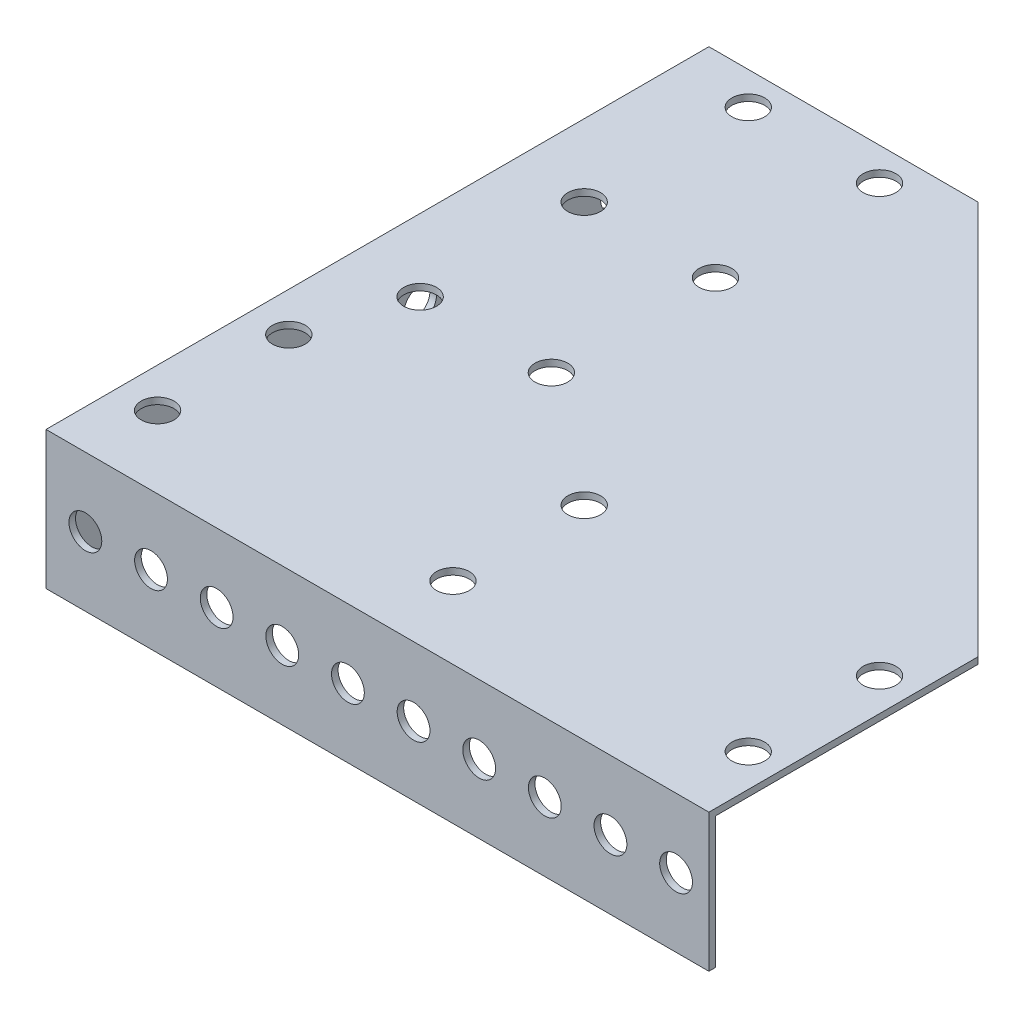
from build123d import *

# Parameters (mm, degrees)
SKETCH1_R           = 2.5
BOSS_EXTRUDE1_DEPTH = 1
SKETCH2_W           = 100
SKETCH2_H           = 21
SKETCH2_R           = 2.5
BOSS_EXTRUDE2_DEPTH = 1
SKETCH3_W           = 101
SKETCH3_H           = 21
SKETCH3_R           = 2.5
BOSS_EXTRUDE5_DEPTH = 1


with BuildPart() as part:
    # Sketch1 → Boss-Extrude1 (new body)
    with BuildSketch(Plane(origin=(0, 0, 0), x_dir=(1, 0, 0), z_dir=(0, 1, 0))):
        Polygon((0, 0), (0, -100), (100, -100), (100, -60), (40, 0), align=None)
        with Locations((10, -5)):
            Circle(SKETCH1_R, mode=Mode.SUBTRACT)
        with Locations((30, -5)):
            Circle(SKETCH1_R, mode=Mode.SUBTRACT)
        with Locations((30, -55)):
            Circle(SKETCH1_R, mode=Mode.SUBTRACT)
        with Locations((10, -55)):
            Circle(SKETCH1_R, mode=Mode.SUBTRACT)
        with Locations((30, -30)):
            Circle(SKETCH1_R, mode=Mode.SUBTRACT)
        with Locations((10, -30)):
            Circle(SKETCH1_R, mode=Mode.SUBTRACT)
        with Locations((50, -70)):
            Circle(SKETCH1_R, mode=Mode.SUBTRACT)
        with Locations((50, -90)):
            Circle(SKETCH1_R, mode=Mode.SUBTRACT)
        with Locations((95, -70)):
            Circle(SKETCH1_R, mode=Mode.SUBTRACT)
        with Locations((95, -90)):
            Circle(SKETCH1_R, mode=Mode.SUBTRACT)
        with Locations((5, -70)):
            Circle(SKETCH1_R, mode=Mode.SUBTRACT)
        with Locations((5, -90)):
            Circle(SKETCH1_R, mode=Mode.SUBTRACT)
    extrude(amount=BOSS_EXTRUDE1_DEPTH)

    # Sketch2 → Boss-Extrude2 (add)
    with BuildSketch(Plane.ZY):
        with Locations((50, -9.5)):
            Rectangle(SKETCH2_W, SKETCH2_H)
        with Locations((5, -10)):
            Circle(SKETCH2_R, mode=Mode.SUBTRACT)
        with Locations((15, -10)):
            Circle(SKETCH2_R, mode=Mode.SUBTRACT)
        with Locations((25, -10)):
            Circle(SKETCH2_R, mode=Mode.SUBTRACT)
        with Locations((35, -10)):
            Circle(SKETCH2_R, mode=Mode.SUBTRACT)
        with Locations((45, -10)):
            Circle(SKETCH2_R, mode=Mode.SUBTRACT)
        with Locations((55, -10)):
            Circle(SKETCH2_R, mode=Mode.SUBTRACT)
        with Locations((65, -10)):
            Circle(SKETCH2_R, mode=Mode.SUBTRACT)
        with Locations((75, -10)):
            Circle(SKETCH2_R, mode=Mode.SUBTRACT)
    extrude(amount=BOSS_EXTRUDE2_DEPTH)

    # Sketch3 → Boss-Extrude5 (add)
    with BuildSketch(Plane.XY.offset(100)):
        with Locations((49.5, -9.5)):
            Rectangle(SKETCH3_W, SKETCH3_H)
        with Locations((95, -9.5)):
            Circle(SKETCH3_R, mode=Mode.SUBTRACT)
        with Locations((85, -9.5)):
            Circle(SKETCH3_R, mode=Mode.SUBTRACT)
        with Locations((75, -9.5)):
            Circle(SKETCH3_R, mode=Mode.SUBTRACT)
        with Locations((65, -9.5)):
            Circle(SKETCH3_R, mode=Mode.SUBTRACT)
        with Locations((55, -9.5)):
            Circle(SKETCH3_R, mode=Mode.SUBTRACT)
        with Locations((45, -9.5)):
            Circle(SKETCH3_R, mode=Mode.SUBTRACT)
        with Locations((35, -9.5)):
            Circle(SKETCH3_R, mode=Mode.SUBTRACT)
        with Locations((25, -9.5)):
            Circle(SKETCH3_R, mode=Mode.SUBTRACT)
        with Locations((15, -9.5)):
            Circle(SKETCH3_R, mode=Mode.SUBTRACT)
        with Locations((5, -9.5)):
            Circle(SKETCH3_R, mode=Mode.SUBTRACT)
    extrude(amount=BOSS_EXTRUDE5_DEPTH)


solid = part.part
